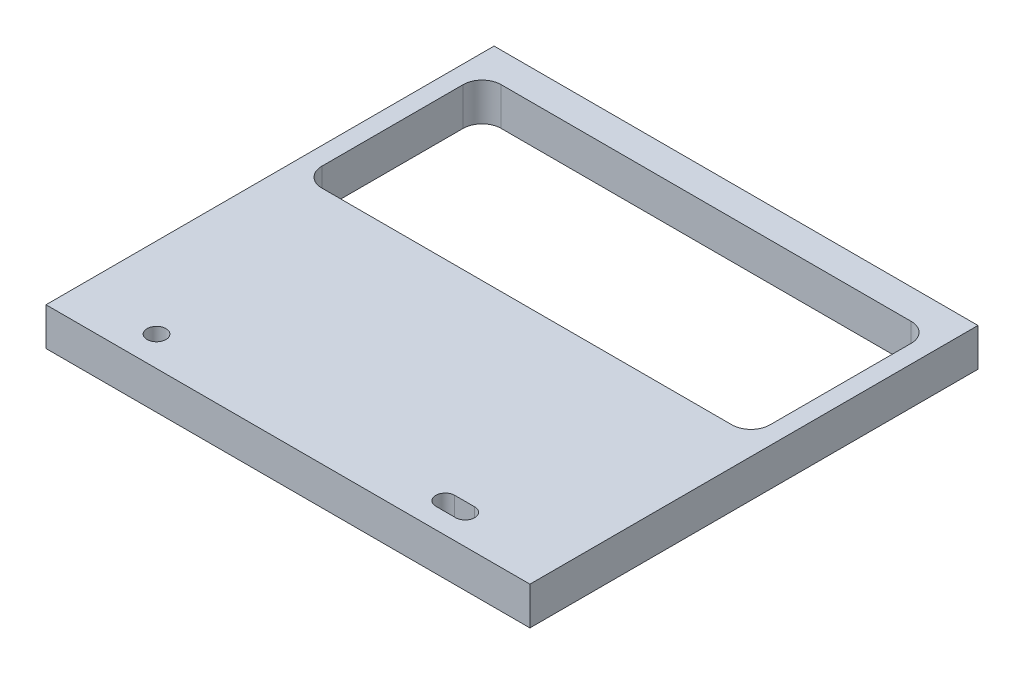
from build123d import *

# Parameters (mm, degrees)
SKETCH1_W           = 81
SKETCH1_H           = 75
SKETCH1_R           = 1.585
BOSS_EXTRUDE1_DEPTH = 6.35


with BuildPart() as part:
    # Sketch1 → Boss-Extrude1 (new body)
    with BuildSketch(Plane(origin=(0, 0, 0), x_dir=(1, 0, 0), z_dir=(0, 1, 0))):
        with Locations((40.5, 37.5)):
            Rectangle(SKETCH1_W, SKETCH1_H)
        with Locations(Location((13.5, 5, 0), (0, 0, 270))):  # turned: the seam where the file's is
            Circle(SKETCH1_R, mode=Mode.SUBTRACT)
        with BuildLine():
            Line((6.175, 40), (74.825, 40))
            ThreePointArc((74.825, 40), (77.07006403, 40.92993597), (78, 43.175))
            Line((78, 43.175), (78, 66.825))
            ThreePointArc((78, 66.825), (77.07006403, 69.07006403), (74.825, 70))
            Line((74.825, 70), (6.175, 70))
            ThreePointArc((6.175, 70), (3.92993597, 69.07006403), (3, 66.825))
            Line((3, 66.825), (3, 43.175))
            ThreePointArc((3, 43.175), (3.92993597, 40.92993597), (6.175, 40))
        make_face(mode=Mode.SUBTRACT)
        with BuildLine():
            Line((61.83, 6.585), (65.17, 6.585))
            ThreePointArc((65.17, 6.585), (66.755, 5), (65.17, 3.415))
            Line((65.17, 3.415), (61.83, 3.415))
            ThreePointArc((61.83, 3.415), (60.245, 5), (61.83, 6.585))
        make_face(mode=Mode.SUBTRACT)
    extrude(amount=BOSS_EXTRUDE1_DEPTH)


solid = part.part
